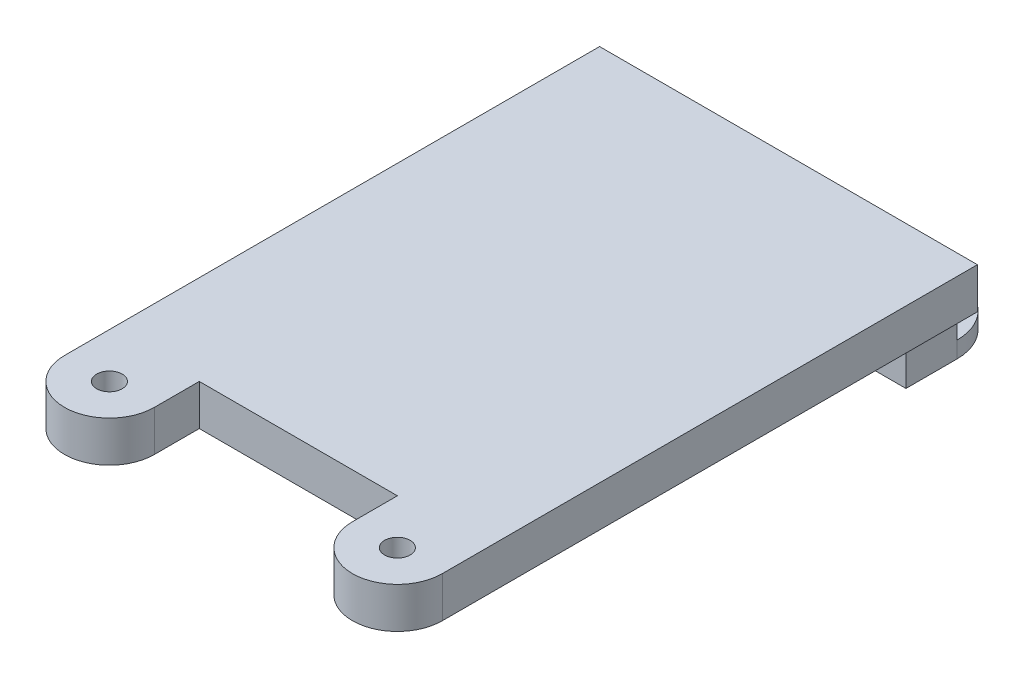
from build123d import *

# Parameters (mm, degrees)
SKETCH1_W           = 18.5
SKETCH1_H           = 24
SKETCH1_R           = 0.625
BOSS_EXTRUDE1_DEPTH = 2
SKETCH2_W           = 16.5
SKETCH2_H           = 2.5
BOSS_EXTRUDE2_DEPTH = 2.5
SKETCH3_W           = 16.5
SKETCH3_H           = 2.5
BOSS_EXTRUDE3_DEPTH = 0.8
FILLET2_R           = 2.5


with BuildPart() as part:
    # Sketch1 → Boss-Extrude1 (new body)
    with BuildSketch(Plane(origin=(0, 0, 0), x_dir=(1, 0, 0), z_dir=(0, 1, 0))):
        Rectangle(SKETCH1_W, SKETCH1_H)
        with BuildLine():
            Line((-4.85, -12), (-9.25, -12))
            Line((-9.25, -12), (-9.25, -14.2))
            ThreePointArc((-9.25, -14.2), (-7.05, -16.4), (-4.85, -14.2))
            Line((-4.85, -14.2), (-4.85, -12))
        make_face()
        with Locations((-7.05, -14.2)):
            Circle(SKETCH1_R, mode=Mode.SUBTRACT)
        with BuildLine():
            Line((9.25, -12), (4.85, -12))
            Line((4.85, -12), (4.85, -14.2))
            ThreePointArc((4.85, -14.2), (7.05, -16.4), (9.25, -14.2))
            Line((9.25, -14.2), (9.25, -12))
        make_face()
        with Locations((7.05, -14.2)):
            Circle(SKETCH1_R, mode=Mode.SUBTRACT)
    extrude(amount=BOSS_EXTRUDE1_DEPTH)

    # Sketch2 → Boss-Extrude2 (add)
    with BuildSketch(Plane.XZ):
        with Locations((0, -10.75)):
            Rectangle(SKETCH2_W, SKETCH2_H)
    extrude(amount=BOSS_EXTRUDE2_DEPTH)

    # Sketch3 → Boss-Extrude3 (add)
    with BuildSketch(Plane(origin=(0, -2.5, 0), x_dir=(-1, 0, 0), z_dir=(0, -1, 0))):
        with Locations((0, 13.25)):
            Rectangle(SKETCH3_W, SKETCH3_H)
    extrude(amount=-BOSS_EXTRUDE3_DEPTH)

    # Fillet2
    fillet2_edges = [part.edges().sort_by_distance(p)[0] for p in [
        (-8.25, -2.1, -14.5),
        (8.25, -2.1, -14.5),
    ]]
    fillet(fillet2_edges, radius=FILLET2_R)


solid = part.part
